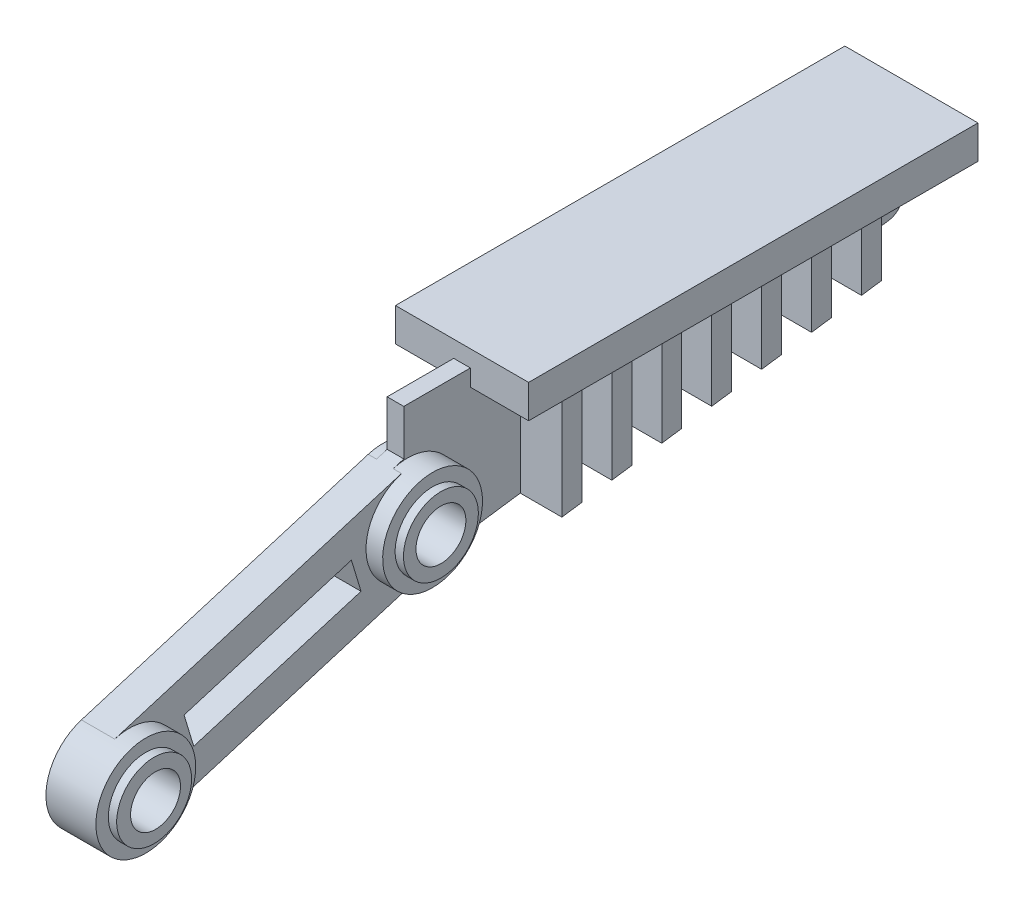
from build123d import *

# Parameters (mm, degrees)
SKETCH1_W           = 8
SKETCH1_H           = 27
BOSS_EXTRUDE1_DEPTH = 2
BOSS_EXTRUDE2_DEPTH = 0.5
BOSS_EXTRUDE3_DEPTH = 0.5
BOSS_EXTRUDE4_DEPTH = 0.5
SKETCH7_R           = 2.25
BOSS_EXTRUDE5_DEPTH = 0.5
SKETCH8_R           = 3
BOSS_EXTRUDE6_DEPTH = 1
SKETCH9_R           = 2.25
BOSS_EXTRUDE7_DEPTH = 0.5
SKETCH10_R          = 1.5
CUT_EXTRUDE1_DEPTH  = 7.5
SKETCH14_W          = 10.5
SKETCH14_H          = 2
CUT_EXTRUDE2_DEPTH  = 1.8
FILLET1_R           = 1
SKETCH15_W          = 4
SKETCH15_H          = 3.5
CUT_EXTRUDE5_DEPTH  = 0.1
SKETCH19_W          = 6
SKETCH19_H          = 1.2
BOSS_EXTRUDE8_DEPTH = 7.1
LPATTERN1_COUNT     = 7
LPATTERN1_PITCH     = 3
SKETCH20_W          = 19.979424
SKETCH20_H          = 3.421259
CUT_EXTRUDE6_DEPTH  = 3.55


with BuildPart() as part:
    # Sketch1 → Boss-Extrude1 (new body)
    with BuildSketch(Plane(origin=(0, 0, 0), x_dir=(1, 0, 0), z_dir=(0, 1, 0))):
        Rectangle(SKETCH1_W, SKETCH1_H)
    extrude(amount=-BOSS_EXTRUDE1_DEPTH)

    # Sketch4 → Boss-Extrude2 (add, symmetric)
    with BuildSketch(Plane(origin=(0, 0, 0), x_dir=(0, 0, -1), z_dir=(1, 0, 0))):
        with BuildLine():
            Line((13.5, 0), (13.5, -2))
            Line((13.5, -2), (12.263932, -5.804226))
            Line((12.263932, -5.804226), (-17.5, -10))
            Line((-17.5, -10), (-33.632717, -14.871902))
            ThreePointArc((-33.632717, -14.871902), (-37.371902, -12.867283), (-35.367283, -9.128098))
            Line((-35.367283, -9.128098), (-19.234565, -4.256196))
            Line((-19.234565, -4.256196), (-17.501224, -3.732746))
            Line((-17.501224, -3.732746), (-17.5, -1))
            Line((-17.5, -1), (-13.5, -1))
            Line((-13.5, -1), (-13.5, 0))
            Line((-13.5, 0), (13.5, 0))
        make_face()
    extrude(amount=BOSS_EXTRUDE2_DEPTH, both=True)

    # Sketch5 → Boss-Extrude3 (add)
    with BuildSketch(Plane.ZY.offset(0.5)):
        with BuildLine():
            Line((33.632717, -14.871902), (16.422266, -9.674453))
            ThreePointArc((16.422266, -9.674453), (14.393544, -5.939496), (18.135871, -3.924403))
            Line((18.135871, -3.924403), (35.367283, -9.128098))
            ThreePointArc((35.367283, -9.128098), (37.371898, -12.867295), (33.632717, -14.871902))
        make_face()
    extrude(amount=BOSS_EXTRUDE3_DEPTH)

    # Sketch6 → Boss-Extrude4 (add)
    with BuildSketch(Plane(origin=(0.5, 0, 0), x_dir=(0, 0, -1), z_dir=(1, 0, 0))):
        with BuildLine():
            Line((-35.367283, -9.128098), (-18.135871, -3.924403))
            ThreePointArc((-18.135871, -3.924403), (-14.396686, -5.929022), (-16.401306, -9.668206))
            Line((-16.401306, -9.668206), (-33.632717, -14.871902))
            ThreePointArc((-33.632717, -14.871902), (-37.371902, -12.867283), (-35.367283, -9.128098))
        make_face()
    extrude(amount=BOSS_EXTRUDE4_DEPTH)

    # Sketch7 → Boss-Extrude5 (add)
    with BuildSketch(Plane.ZY.offset(1)):
        with Locations((17.268588, -6.796304)):
            Circle(SKETCH7_R)
    extrude(amount=BOSS_EXTRUDE5_DEPTH)

    # Sketch8 → Boss-Extrude6 (add)
    with BuildSketch(Plane(origin=(1, 0, 0), x_dir=(0, 0, -1), z_dir=(1, 0, 0))):
        with Locations((-34.5, -12)):
            Circle(SKETCH8_R)
        with Locations((-17.268588, -6.796304)):
            Circle(SKETCH8_R)
    extrude(amount=BOSS_EXTRUDE6_DEPTH)

    # Sketch9 → Boss-Extrude7 (add)
    with BuildSketch(Plane(origin=(2, 0, 0), x_dir=(0, 0, -1), z_dir=(1, 0, 0))):
        with Locations((-34.5, -12)):
            Circle(SKETCH9_R)
        with Locations((-17.268588, -6.796304)):
            Circle(SKETCH9_R)
    extrude(amount=BOSS_EXTRUDE7_DEPTH)

    # Sketch10 → Cut-Extrude1 (cut, through all)
    with BuildSketch(Plane(origin=(2.5, 0, 0), x_dir=(0, 0, -1), z_dir=(1, 0, 0))):
        with Locations((-17.268588, -6.796304)):
            Circle(SKETCH10_R)
        with Locations((-34.415724, -12.051332)):
            Circle(SKETCH10_R)
    extrude(amount=-CUT_EXTRUDE1_DEPTH, mode=Mode.SUBTRACT)

    # Sketch14 → Cut-Extrude2 (cut)
    with BuildSketch(Plane(origin=(1, 0, 0), x_dir=(0, 0.289094, -0.957301), z_dir=(-1, 0, 0))):
        with Locations((-27.496003, 1.513858)):
            Rectangle(SKETCH14_W, SKETCH14_H)
    extrude(amount=CUT_EXTRUDE2_DEPTH, mode=Mode.SUBTRACT)

    # Fillet1
    fillet1_edges = [part.edges().sort_by_distance(p)[0] for p in [
        (0, -5.804226, -12.263932),
    ]]
    fillet(fillet1_edges, radius=FILLET1_R)

    # Sketch15 → Cut-Extrude5 (cut)
    with BuildSketch(Plane(origin=(-1, 0, 0), x_dir=(0, 0.289098, -0.957299), z_dir=(1, 0, 0))):
        with Locations((-27.49601, -1.513736)):
            Rectangle(SKETCH15_W, SKETCH15_H)
    extrude(amount=CUT_EXTRUDE5_DEPTH, mode=Mode.SUBTRACT)

    # Sketch19 → Boss-Extrude8 (add)
    with BuildSketch(Plane.XZ.offset(2)):
        with Locations((0, 9.9)):
            Rectangle(SKETCH19_W, SKETCH19_H)
    boss_extrude8 = extrude(amount=BOSS_EXTRUDE8_DEPTH)

    # LPattern1: Boss-Extrude8 ×7
    with Locations(*[(0, 0, -i * LPATTERN1_PITCH) for i in range(1, LPATTERN1_COUNT)]):
        add(boss_extrude8)

    # Sketch20 → Cut-Extrude6 (cut, symmetric)
    with BuildSketch(Plane(origin=(0.5, 0, 0), x_dir=(0, 0.139588, -0.99021), z_dir=(-1, 0, 0))):
        with Locations((-2.255219, 9.169932)):
            Rectangle(SKETCH20_W, SKETCH20_H)
    extrude(amount=CUT_EXTRUDE6_DEPTH, both=True, mode=Mode.SUBTRACT)


solid = part.part
